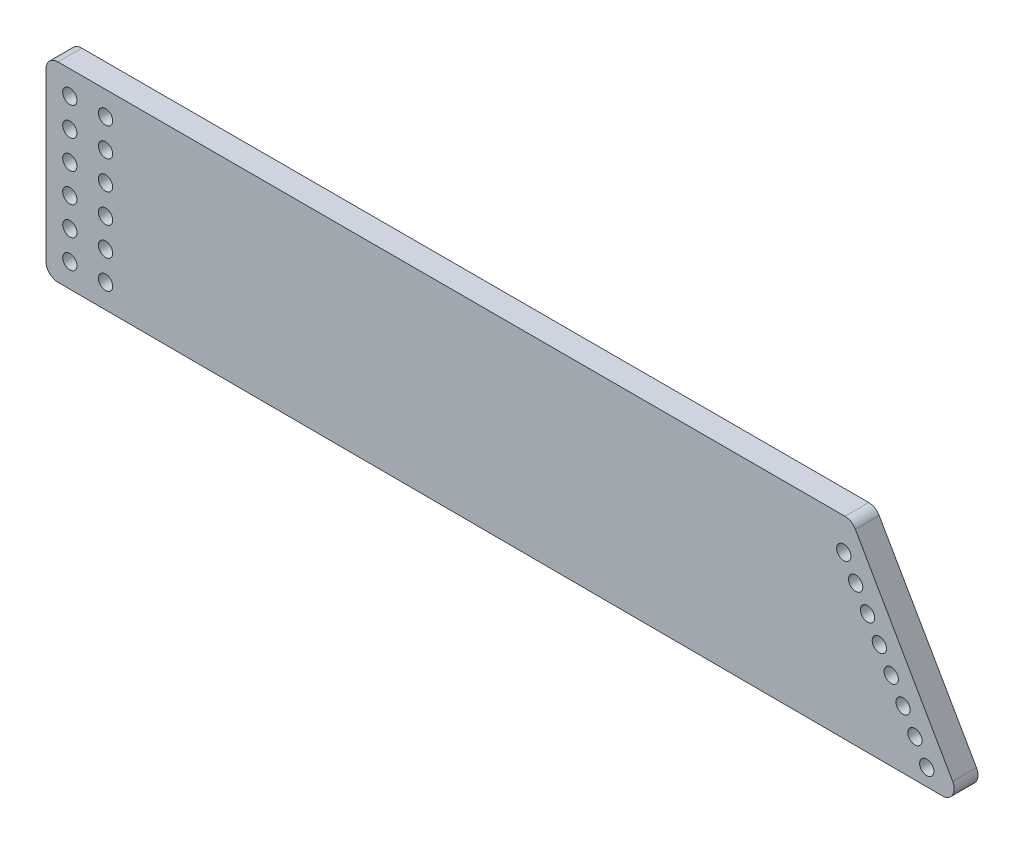
from build123d import *

# Parameters (mm, degrees)
BOSS_EXTRUDE1_DEPTH = 10
FILLET1_R           = 5
SKETCH2_R           = 3
CUT_EXTRUDE1_DEPTH  = 15


with BuildPart() as part:
    # Sketch1 → Boss-Extrude1 (new body)
    with BuildSketch(Plane.XY):
        Polygon((-169.15, 40.054759159), (169.15, 40.054759159), (215.74113672, -41.201675672), (-169.15, -40.054759159), align=None)
    extrude(amount=BOSS_EXTRUDE1_DEPTH)

    # Fillet1
    fillet1_edges = [part.edges().sort_by_distance(p)[0] for p in [
        (-169.15, 40.054759159, 5),
        (169.15, 40.054759159, 5),
        (215.74113672, -41.201675672, 5),
        (-169.15, -40.054759159, 5),
    ]]
    fillet(fillet1_edges, radius=FILLET1_R)

    # Sketch2 → Cut-Extrude1 (cut)
    with BuildSketch(Plane(origin=(0, 0, 0), x_dir=(-1, 0, 0), z_dir=(0, 0, -1))):
        with Locations((144.15, 30.054759159)):
            Circle(SKETCH2_R)
        with Locations((159.15, 30.054759159)):
            Circle(SKETCH2_R)
        with Locations((159.15, 18.054759159)):
            Circle(SKETCH2_R)
        with Locations((159.15, 6.054759159)):
            Circle(SKETCH2_R)
        with Locations((144.15, 18.054759159)):
            Circle(SKETCH2_R)
        with Locations((144.15, 6.054759159)):
            Circle(SKETCH2_R)
        with Locations((144.149466916, -6.067437377)):
            Circle(SKETCH2_R)
        with Locations((144.148411495, -18.06743733)):
            Circle(SKETCH2_R)
        with Locations((159.149466858, -6.068756652)):
            Circle(SKETCH2_R)
        with Locations((159.148411437, -18.068756606)):
            Circle(SKETCH2_R)
        with Locations((159.147356017, -30.06875656)):
            Circle(SKETCH2_R)
        with Locations((144.147356075, -30.067437284)):
            Circle(SKETCH2_R)
        with Locations((-165.763069515, 26.671271591)):
            Circle(SKETCH2_R)
        with Locations((-195.608099644, -25.379416941)):
            Circle(SKETCH2_R)
        with Locations((-190.633927956, -16.704302185)):
            Circle(SKETCH2_R)
        with Locations((-185.659756267, -8.02918743)):
            Circle(SKETCH2_R)
        with Locations((-180.685584579, 0.645927325)):
            Circle(SKETCH2_R)
        with Locations((-175.711412891, 9.32104208)):
            Circle(SKETCH2_R)
        with Locations((-170.737241203, 17.996156836)):
            Circle(SKETCH2_R)
        with Locations((-200.582271332, -34.054531696)):
            Circle(SKETCH2_R)
    extrude(amount=-CUT_EXTRUDE1_DEPTH, mode=Mode.SUBTRACT)


solid = part.part
